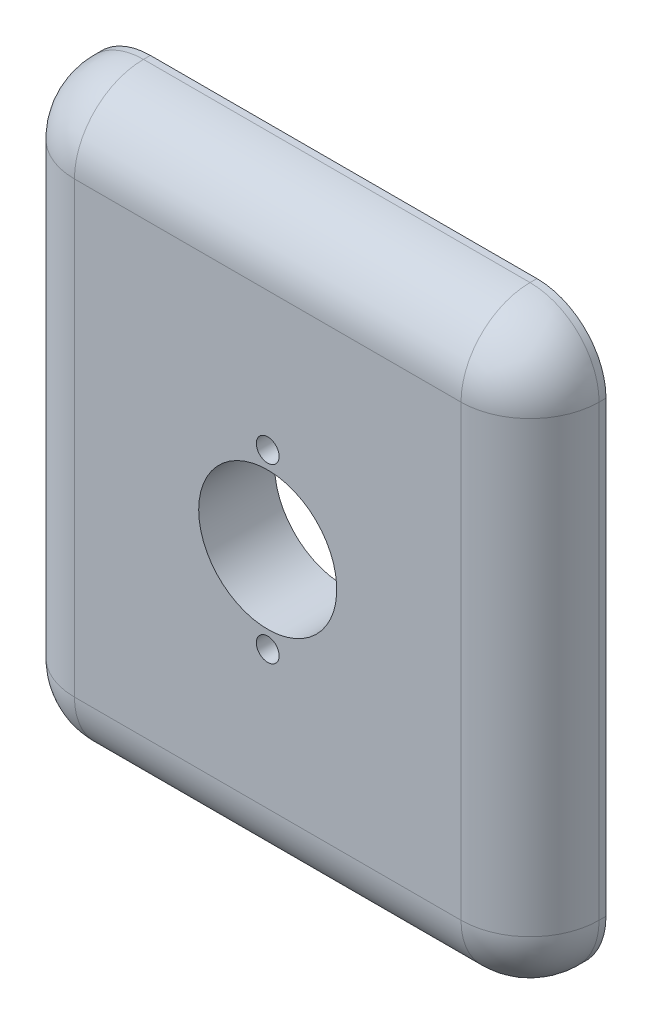
from build123d import *

# Parameters (mm, degrees)
CROQUIS1_W              = 76
CROQUIS1_H              = 85
SALIENTE_EXTRUIR1_DEPTH = 11
CROQUIS3_R              = 1.65
CORTAR_EXTRUIR2_DEPTH   = 5
CROQUIS4_R              = 3
CORTAR_EXTRUIR3_DEPTH   = 2
REDONDEO3_R             = 10
CROQUIS5_R              = 10
CROQUIS5_R_2            = 1.65
CORTAR_EXTRUIR4_DEPTH   = 12


with BuildPart() as part:
    # Croquis1 → Saliente-Extruir1 (new body)
    with BuildSketch(Plane.XY):
        Rectangle(CROQUIS1_W, CROQUIS1_H)
    extrude(amount=SALIENTE_EXTRUIR1_DEPTH)

    # Croquis3 → Cortar-Extruir2 (cut)
    with BuildSketch(Plane(origin=(0, 0, 0), x_dir=(-1, 0, 0), z_dir=(0, 0, -1))):
        with Locations((28, -28)):
            Circle(CROQUIS3_R)
        with Locations((-28, -28)):
            Circle(CROQUIS3_R)
        with Locations((-28, 28)):
            Circle(CROQUIS3_R)
        with Locations((28, 28)):
            Circle(CROQUIS3_R)
    extrude(amount=-CORTAR_EXTRUIR2_DEPTH, mode=Mode.SUBTRACT)

    # Croquis4 → Cortar-Extruir3 (cut)
    with BuildSketch(Plane(origin=(0, 0, 0), x_dir=(-1, 0, 0), z_dir=(0, 0, -1))):
        with Locations((28, 28)):
            Circle(CROQUIS4_R)
        with Locations((28, -28)):
            Circle(CROQUIS4_R)
        with Locations((-28, 28)):
            Circle(CROQUIS4_R)
        with Locations((-28, -28)):
            Circle(CROQUIS4_R)
    extrude(amount=-CORTAR_EXTRUIR3_DEPTH, mode=Mode.SUBTRACT)

    # Redondeo3
    redondeo3_edges = [part.edges().sort_by_distance(p)[0] for p in [
        (38, 0, 11),
        (0, 42.5, 11),
        (-38, 0, 11),
        (0, -42.5, 11),
        (-38, 42.5, 5.5),
        (38, 42.5, 5.5),
        (38, -42.5, 5.5),
        (-38, -42.5, 5.5),
    ]]
    fillet(redondeo3_edges, radius=REDONDEO3_R)

    # Croquis5 → Cortar-Extruir4 (cut, through all)
    with BuildSketch(Plane(origin=(0, 0, 0), x_dir=(-1, 0, 0), z_dir=(0, 0, -1))):
        Circle(CROQUIS5_R)
        with Locations((0, 12.5)):
            Circle(CROQUIS5_R_2)
        with Locations((0, -12.5)):
            Circle(CROQUIS5_R_2)
    extrude(amount=-CORTAR_EXTRUIR4_DEPTH, mode=Mode.SUBTRACT)


solid = part.part
